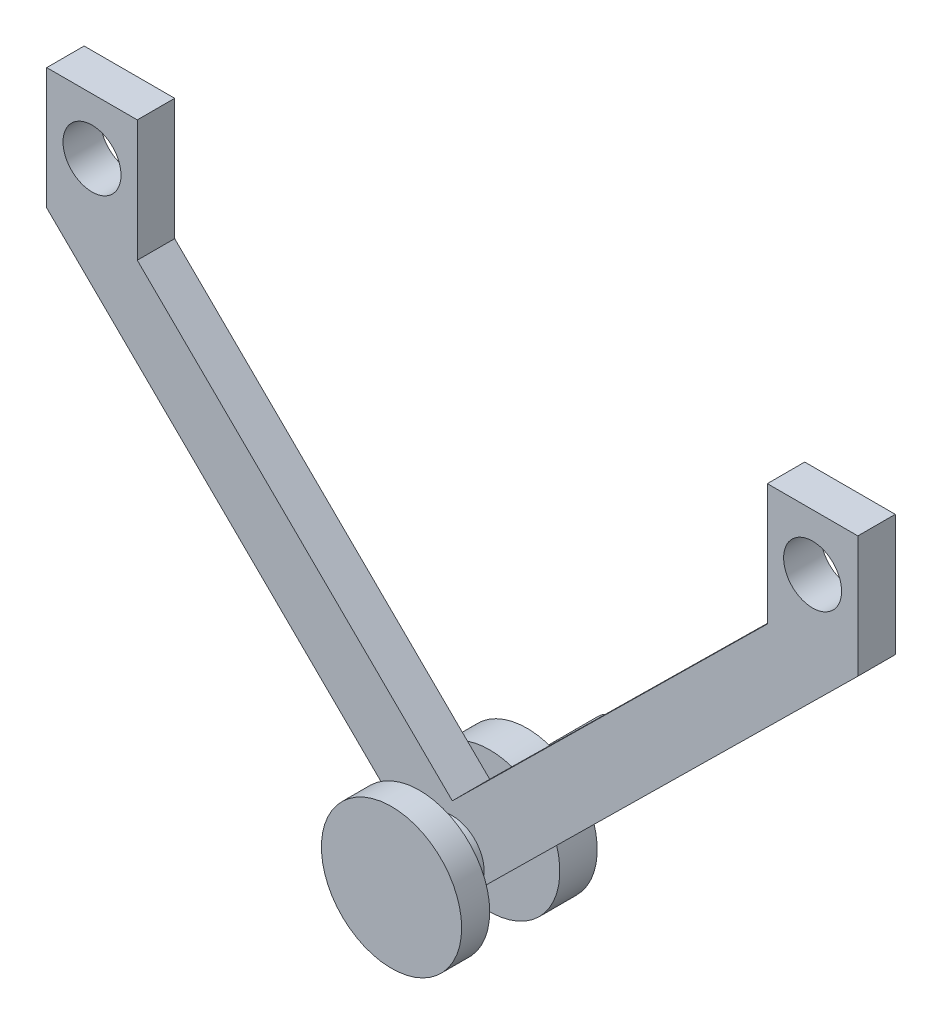
from build123d import *

# Parameters (mm, degrees)
SKETCH_1_R          = 7.5
EXTRUDE_1_DEPTH     = 3
SKETCH_2_R          = 3.4
EXTRUDE_2_DEPTH     = 11.5
SKETCH_3_R          = 7.5
EXTRUDE_3_DEPTH     = 4
SKETCH_4_R          = 3.4
EXTRUDE_4_DEPTH     = 10
EXTRUDE_5_DEPTH     = 4
SKETCH_7_R          = 3.1
CUT_EXTRUDE_1_DEPTH = 11.5


with BuildPart() as part:
    # Эскиз1 → Бобышка-Вытянуть1 (new body)
    with BuildSketch(Plane.XY):
        Circle(SKETCH_1_R)
    extrude(amount=-EXTRUDE_1_DEPTH)

    # Эскиз2 → Бобышка-Вытянуть2 (add)
    with BuildSketch(Plane(origin=(0, 0, -3), x_dir=(-1, 0, 0), z_dir=(0, 0, -1))):
        Circle(SKETCH_2_R)
    extrude(amount=EXTRUDE_2_DEPTH)

    # Эскиз3 → Бобышка-Вытянуть3 (add)
    with BuildSketch(Plane(origin=(0, 0, -14.5), x_dir=(-1, 0, 0), z_dir=(0, 0, -1))):
        Circle(SKETCH_3_R)
    extrude(amount=-EXTRUDE_3_DEPTH)

    # Эскиз4 → Бобышка-Вытянуть4 (add)
    with BuildSketch(Plane(origin=(0, 0, -14.5), x_dir=(-1, 0, 0), z_dir=(0, 0, -1))):
        Circle(SKETCH_4_R)
    extrude(amount=EXTRUDE_4_DEPTH)

    # Эскиз6 → Бобышка-Вытянуть5 (add)
    with BuildSketch(Plane.XY.offset(-10.5)):
        with BuildLine():
            Line((-33.690694721, 51), (-33.690694721, 38))
            Line((-33.690694721, 38), (0, 4.775195955))
            Line((0, 4.775195955), (33.690694721, 38))
            Line((33.690694721, 38), (33.690694721, 51))
            Line((33.690694721, 51), (43.375005813, 51))
            Line((43.375005813, 51), (43.375005813, 38))
            Line((43.375005813, 38), (2.387366513, -2.420843062))
            ThreePointArc((2.387366513, -2.420843062), (0, -3.4), (-2.387366513, -2.420843062))
            Line((-2.387366513, -2.420843062), (-43.375005813, 38))
            Line((-43.375005813, 38), (-43.375005813, 51))
            Line((-43.375005813, 51), (-33.690694721, 51))
        make_face()
    extrude(amount=EXTRUDE_5_DEPTH)

    # Эскиз7 → Вырез-Вытянуть1 (cut, through all)
    with BuildSketch(Plane(origin=(0, 0, -10.5), x_dir=(-1, 0, 0), z_dir=(0, 0, -1))):
        with Locations((-38.532850267, 45)):
            Circle(SKETCH_7_R)
        with Locations((38.532850267, 45)):
            Circle(SKETCH_7_R)
    extrude(amount=-CUT_EXTRUDE_1_DEPTH, mode=Mode.SUBTRACT)


solid = part.part
